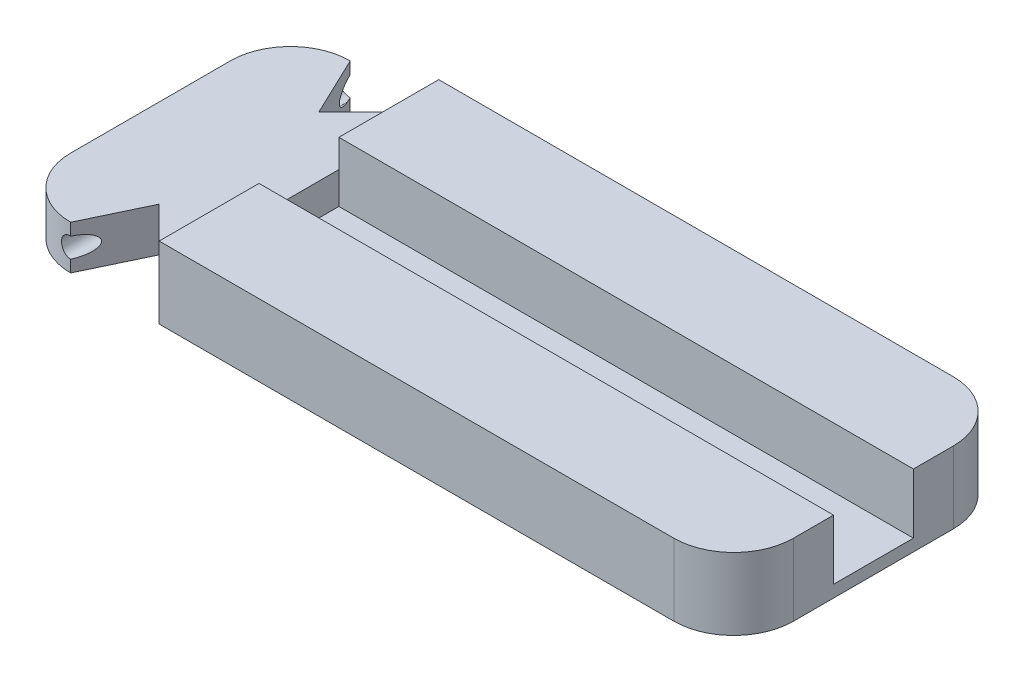
from build123d import *

# Parameters (mm, degrees)
BOSS_EXTRUDE1_DEPTH = 18
CUT_EXTRUDE1_DEPTH  = 18
CUT_EXTRUDE2_DEPTH  = 18
SKETCH4_W           = 45.12531779
SKETCH4_H           = 70
CUT_EXTRUDE3_DEPTH  = 7
SKETCH5_R           = 2.5
CUT_EXTRUDE4_DEPTH  = 70
SKETCH6_W           = 143.844268465
SKETCH6_H           = 20
CUT_EXTRUDE5_DEPTH  = 15


with BuildPart() as part:
    # Sketch1 → Boss-Extrude1 (new body)
    with BuildSketch(Plane(origin=(0, 0, 0), x_dir=(1, 0, 0), z_dir=(0, 1, 0))):
        with BuildLine():
            Line((-90.5, -20), (-90.5, 20))
            ThreePointArc((-90.5, 20), (-86.106601718, 30.606601718), (-75.5, 35))
            Line((-75.5, 35), (75.5, 35))
            ThreePointArc((75.5, 35), (86.106601718, 30.606601718), (90.5, 20))
            Line((90.5, 20), (90.5, -20))
            ThreePointArc((90.5, -20), (86.106601718, -30.606601718), (75.5, -35))
            Line((75.5, -35), (-75.5, -35))
            ThreePointArc((-75.5, -35), (-86.106601718, -30.606601718), (-90.5, -20))
        make_face()
    extrude(amount=BOSS_EXTRUDE1_DEPTH)

    # Sketch3 → Cut-Extrude1 (cut)
    with BuildSketch(Plane(origin=(0, 18, 0), x_dir=(1, 0, 0), z_dir=(0, 1, 0))):
        Polygon((-75.5, 35), (-68.344268465, 20), (-53.344268465, 35), align=None)
    extrude(amount=-CUT_EXTRUDE1_DEPTH, mode=Mode.SUBTRACT)

    # Sketch3_3 → Cut-Extrude2 (cut)
    with BuildSketch(Plane(origin=(0, 18, 0), x_dir=(1, 0, 0), z_dir=(0, 1, 0))):
        Polygon((-75.5, 35), (-68.344268465, 20), (-53.344268465, 35), align=None)
        Polygon((-75.5, -35), (-68.344268465, -20), (-53.344268465, -35), align=None)
    extrude(amount=-CUT_EXTRUDE2_DEPTH, mode=Mode.SUBTRACT)

    # Sketch4 → Cut-Extrude3 (cut)
    with BuildSketch(Plane(origin=(0, 18, 0), x_dir=(1, 0, 0), z_dir=(0, 1, 0))):
        with Locations((-75.90692736, 0)):
            Rectangle(SKETCH4_W, SKETCH4_H)
    extrude(amount=-CUT_EXTRUDE3_DEPTH, mode=Mode.SUBTRACT)

    # Sketch5 → Cut-Extrude4 (cut)
    with BuildSketch(Plane.XY.offset(35)):
        with Locations((-75.5, 5.5)):
            Circle(SKETCH5_R)
    extrude(amount=-CUT_EXTRUDE4_DEPTH, mode=Mode.SUBTRACT)

    # Sketch6 → Cut-Extrude5 (cut)
    with BuildSketch(Plane(origin=(0, 18, 0), x_dir=(1, 0, 0), z_dir=(0, 1, 0))):
        with Locations((18.577865767, 0)):
            Rectangle(SKETCH6_W, SKETCH6_H)
    extrude(amount=-CUT_EXTRUDE5_DEPTH, mode=Mode.SUBTRACT)


solid = part.part
